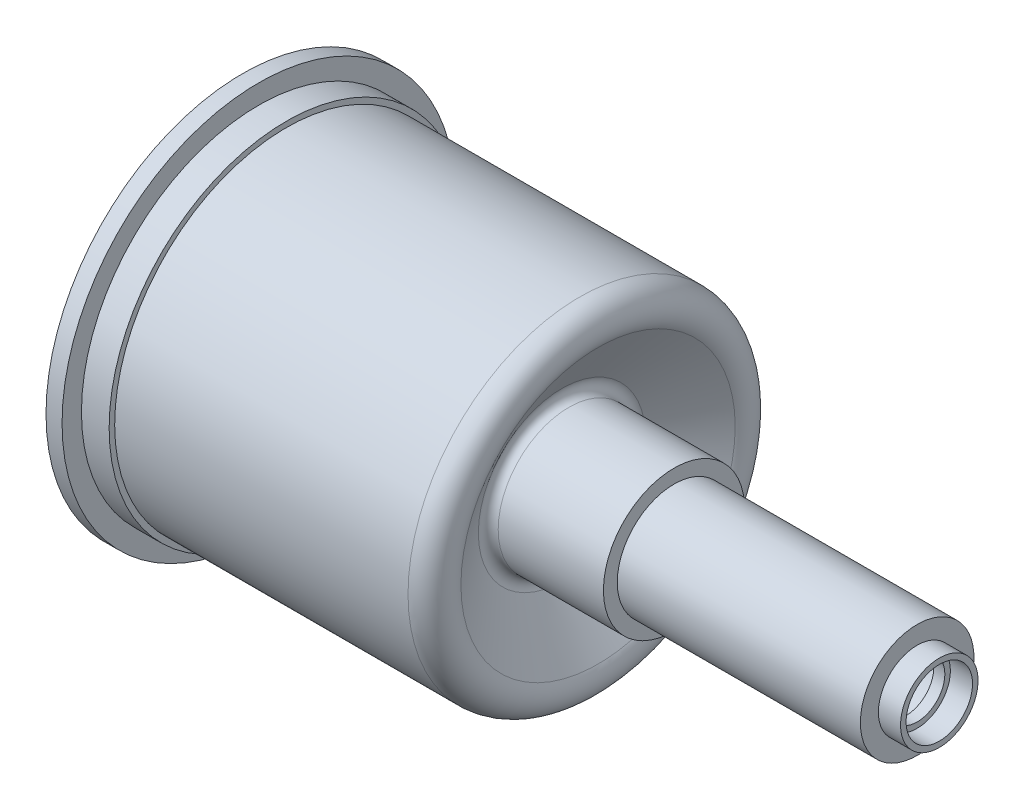
from build123d import *

# Parameters (mm, degrees)
SHELL2_T           = -1.016
SKETCH2_R          = 3.048
CUT_EXTRUDE1_DEPTH = 2.032
SKETCH3_W          = 1.4732
SKETCH3_H          = 3.81
SKETCH5_W          = 2.54
SKETCH5_H          = 0.508


with BuildPart() as part:
    # Sketch1 → Revolve1 (revolve)
    with BuildSketch(Plane.XY, mode=Mode.PRIVATE) as revolve1_sk:
        with BuildLine():
            Line((0, 15.748), (29.447773474, 15.748))
            ThreePointArc((29.447773474, 15.748), (31.242, 14.669821353), (31.132194313, 12.579448005))
            Line((31.132194313, 12.579448005), (27.816342185, 7.665206998))
            ThreePointArc((27.816342185, 7.665206998), (27.775165053, 6.881316993), (28.448, 6.477))
            Line((28.448, 6.477), (38.1, 6.477))
            Line((38.1, 6.477), (38.1, 5.207))
            Line((38.1, 5.207), (60.4012, 5.207))
            Line((60.4012, 5.207), (60.4012, 3.556))
            Line((60.4012, 3.556), (62.4332, 3.556))
            Line((62.4332, 3.556), (62.4332, 0))
            Line((62.4332, 0), (0, 0))
            Line((0, 0), (0, 15.748))
        make_face()
    revolve(revolve1_sk.sketch.rotate(Axis((-43.926024549, 0, 0), (1, 0, 0)), 90), axis=Axis((-43.926024549, 0, 0), (1, 0, 0)))

    # Shell2
    shell2_openings = [part.faces().sort_by_distance(p)[0] for p in [
        (0, 0, 0),
    ]]
    offset(amount=SHELL2_T, openings=shell2_openings, kind=Kind.INTERSECTION)

    # Sketch2 → Cut-Extrude1 (cut)
    with BuildSketch(Plane(origin=(62.4332, 0, 0), x_dir=(0, 0, -1), z_dir=(1, 0, 0))):
        Circle(SKETCH2_R)
    extrude(amount=-CUT_EXTRUDE1_DEPTH, mode=Mode.SUBTRACT)

    # Sketch3 → Revolve2 (revolve)
    with BuildSketch(Plane.XY, mode=Mode.PRIVATE) as revolve2_sk:
        with Locations((-0.7366, 16.129)):
            Rectangle(SKETCH3_W, SKETCH3_H)
    revolve(revolve2_sk.sketch.rotate(Axis((-13.470547245, 0, 0), (1, 0, 0)), 90), axis=Axis((-13.470547245, 0, 0), (1, 0, 0)))

    # Sketch5 → Revolve4 (revolve)
    with BuildSketch(Plane.XY, mode=Mode.PRIVATE) as revolve4_sk:
        with Locations((1.27, 16.002)):
            Rectangle(SKETCH5_W, SKETCH5_H)
    revolve(revolve4_sk.sketch.rotate(Axis((-12.075404137, 0, 0), (1, 0, 0)), 90), axis=Axis((-12.075404137, 0, 0), (1, 0, 0)))


solid = part.part
